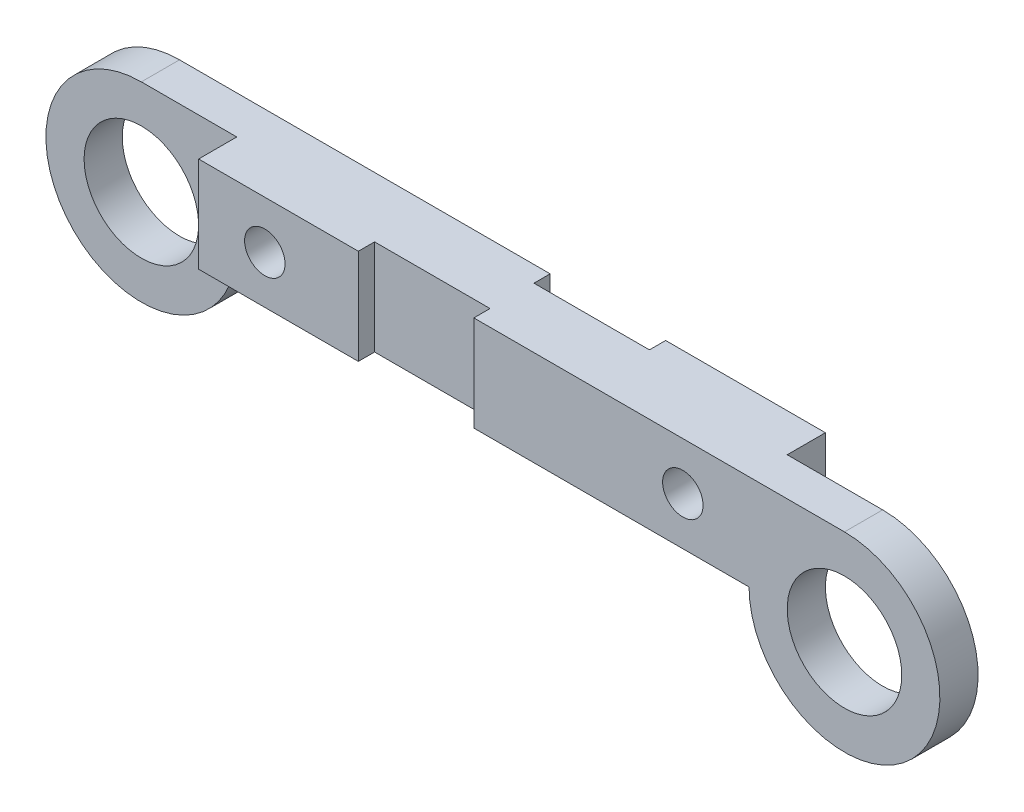
from build123d import *

# Parameters (mm, degrees)
SKETCH1_R           = 15
BOSS_EXTRUDE1_DEPTH = 20
SKETCH2_W           = 50
SKETCH2_H           = 10
CUT_EXTRUDE1_DEPTH  = 84
SKETCH3_R           = 5.297885383
CUT_EXTRUDE2_DEPTH  = 20
SKETCH4_W           = 30.252743008
SKETCH4_H           = 4.249478602
CUT_EXTRUDE3_DEPTH  = 31


with BuildPart() as part:
    # Sketch1 → Boss-Extrude1 (new body)
    with BuildSketch(Plane.XY):
        with BuildLine():
            Line((-72.1, -25), (72.1, -25))
            ThreePointArc((72.1, -25), (114.77766953, -42.67766953), (97.1, 0))
            Line((97.1, 0), (-97.1, 0))
            ThreePointArc((-97.1, 0), (-114.77766953, -42.67766953), (-72.1, -25))
        make_face()
        with Locations((-97.1, -25)):
            Circle(SKETCH1_R, mode=Mode.SUBTRACT)
        with Locations((97.1, -25)):
            Circle(SKETCH1_R, mode=Mode.SUBTRACT)
    extrude(amount=BOSS_EXTRUDE1_DEPTH)

    # Sketch2 → Cut-Extrude1 (cut)
    with BuildSketch(Plane(origin=(0, 0, 0), x_dir=(1, 0, 0), z_dir=(0, 1, 0))):
        with Locations((97.1, -5)):
            Rectangle(SKETCH2_W, SKETCH2_H)
        with Locations((-97.1, -15)):
            Rectangle(SKETCH2_W, SKETCH2_H)
    extrude(amount=-CUT_EXTRUDE1_DEPTH, mode=Mode.SUBTRACT)

    # Sketch3 → Cut-Extrude2 (cut)
    with BuildSketch(Plane.XY.offset(20)):
        with Locations((-54.754964617, -12.5)):
            Circle(SKETCH3_R)
        with Locations((54.754964617, -12.5)):
            Circle(SKETCH3_R)
    extrude(amount=-CUT_EXTRUDE2_DEPTH, mode=Mode.SUBTRACT)

    # Sketch4 → Cut-Extrude3 (cut)
    with BuildSketch(Plane(origin=(0, 0, 0), x_dir=(1, 0, 0), z_dir=(0, 1, 0))):
        with Locations((-15.126371504, -17.875260699)):
            Rectangle(SKETCH4_W, SKETCH4_H)
        with Locations((15.126371504, -2.124739301)):
            Rectangle(SKETCH4_W, SKETCH4_H)
    extrude(amount=-CUT_EXTRUDE3_DEPTH, mode=Mode.SUBTRACT)


solid = part.part
